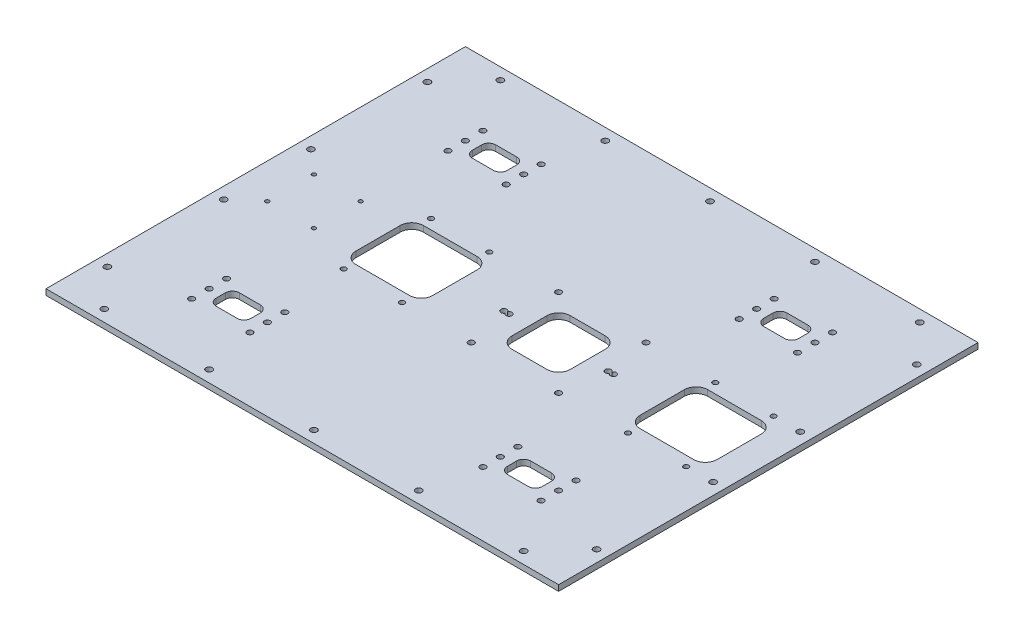
from build123d import *

# Parameters (mm, degrees)
ESQUISSE1_W             = 440
ESQUISSE1_H             = 360
ESQUISSE1_R             = 2.7
BOSS_EXTRU_1_DEPTH      = 5
ESQUISSE2_R             = 1.7
ESQUISSE2_R_2           = 2.5
ESQUISSE2_R_3           = 2.2
ESQUISSE2_W             = 66
ESQUISSE2_H             = 58
ESQUISSE2_W_2           = 50
ESQUISSE2_H_2           = 50
ENL_V_MAT_EXTRU_1_DEPTH = 6
CONG_1_R                = 10
ESQUISSE4_R             = 2.5
ESQUISSE4_W             = 30
ESQUISSE4_H             = 20
ENL_V_MAT_EXTRU_2_DEPTH = 10
CONG_2_R                = 6


with BuildPart() as part:
    # Esquisse1 → Boss.-Extru.1 (new body)
    with BuildSketch(Plane(origin=(0, 0, 0), x_dir=(1, 0, 0), z_dir=(0, 1, 0))):
        with Locations((220, 180)):
            Rectangle(ESQUISSE1_W, ESQUISSE1_H)
        with Locations((40, 350)):
            Circle(ESQUISSE1_R, mode=Mode.SUBTRACT)
        with Locations((130, 350)):
            Circle(ESQUISSE1_R, mode=Mode.SUBTRACT)
        with Locations((220, 350)):
            Circle(ESQUISSE1_R, mode=Mode.SUBTRACT)
        with Locations((310, 350)):
            Circle(ESQUISSE1_R, mode=Mode.SUBTRACT)
        with Locations((400, 350)):
            Circle(ESQUISSE1_R, mode=Mode.SUBTRACT)
        with Locations((400, 10)):
            Circle(ESQUISSE1_R, mode=Mode.SUBTRACT)
        with Locations((310, 10)):
            Circle(ESQUISSE1_R, mode=Mode.SUBTRACT)
        with Locations((220, 10)):
            Circle(ESQUISSE1_R, mode=Mode.SUBTRACT)
        with Locations((130, 10)):
            Circle(ESQUISSE1_R, mode=Mode.SUBTRACT)
        with Locations((40, 10)):
            Circle(ESQUISSE1_R, mode=Mode.SUBTRACT)
        with Locations((10, 217.36725867)):
            Circle(ESQUISSE1_R, mode=Mode.SUBTRACT)
        with Locations((10, 317.36725867)):
            Circle(ESQUISSE1_R, mode=Mode.SUBTRACT)
        with Locations((10, 42.63274133)):
            Circle(ESQUISSE1_R, mode=Mode.SUBTRACT)
        with Locations((10, 142.63274133)):
            Circle(ESQUISSE1_R, mode=Mode.SUBTRACT)
        with Locations((430, 142.63274133)):
            Circle(ESQUISSE1_R, mode=Mode.SUBTRACT)
        with Locations((430, 42.63274133)):
            Circle(ESQUISSE1_R, mode=Mode.SUBTRACT)
        with Locations((430, 317.36725867)):
            Circle(ESQUISSE1_R, mode=Mode.SUBTRACT)
        with Locations((430, 217.36725867)):
            Circle(ESQUISSE1_R, mode=Mode.SUBTRACT)
    extrude(amount=BOSS_EXTRU_1_DEPTH)

    # Esquisse2 → Enlèv. mat.-Extru.1 (cut, through all)
    with BuildSketch(Plane(origin=(0, 5, 0), x_dir=(1, 0, 0), z_dir=(0, 1, 0))):
        with Locations((30, 200)):
            Circle(ESQUISSE2_R)
        with Locations((70, 200)):
            Circle(ESQUISSE2_R)
        with Locations((70, 160)):
            Circle(ESQUISSE2_R)
        with Locations((30, 160)):
            Circle(ESQUISSE2_R)
        with Locations((222.5, 217.5)):
            Circle(ESQUISSE2_R_2)
        with Locations((297.5, 217.5)):
            Circle(ESQUISSE2_R_2)
        with Locations((222.5, 142.5)):
            Circle(ESQUISSE2_R_2)
        with Locations((297.5, 142.5)):
            Circle(ESQUISSE2_R_2)
        with Locations((407, 142.5)):
            Circle(ESQUISSE2_R_3)
        with Locations((357, 142.5)):
            Circle(ESQUISSE2_R_3)
        with Locations((357, 217.5)):
            Circle(ESQUISSE2_R_3)
        with Locations((407, 217.5)):
            Circle(ESQUISSE2_R_3)
        with Locations((163, 142.5)):
            Circle(ESQUISSE2_R_3)
        with Locations((113, 142.5)):
            Circle(ESQUISSE2_R_3)
        with Locations((113, 217.5)):
            Circle(ESQUISSE2_R_3)
        with Locations((163, 217.5)):
            Circle(ESQUISSE2_R_3)
        with Locations((138, 180)):
            Rectangle(ESQUISSE2_W, ESQUISSE2_H)
        with Locations((382, 180)):
            Rectangle(ESQUISSE2_W, ESQUISSE2_H)
        with Locations((260, 180)):
            Rectangle(ESQUISSE2_W_2, ESQUISSE2_H_2)
        with BuildLine():
            ThreePointArc((215.25, 181.089724736), (210.5, 180), (215.25, 178.910275264))
            ThreePointArc((215.25, 178.910275264), (220, 180), (215.25, 181.089724736))
        make_face()
        with BuildLine():
            ThreePointArc((304.75, 178.910275264), (309.5, 180), (304.75, 181.089724736))
            ThreePointArc((304.75, 181.089724736), (300, 180), (304.75, 178.910275264))
        make_face()
    extrude(amount=-ENL_V_MAT_EXTRU_1_DEPTH, mode=Mode.SUBTRACT)

    # Congé1
    cong_1_edges = [part.edges().sort_by_distance(p)[0] for p in [
        (415, 2.5, -209),
        (415, 2.5, -151),
        (349, 2.5, -151),
        (349, 2.5, -209),
        (105, 2.5, -151),
        (105, 2.5, -209),
        (171, 2.5, -209),
        (171, 2.5, -151),
        (285, 2.5, -205),
        (285, 2.5, -155),
        (235, 2.5, -155),
        (235, 2.5, -205),
    ]]
    fillet(cong_1_edges, radius=CONG_1_R)

    # Esquisse4 → Enlèv. mat.-Extru.2 (cut)
    with BuildSketch(Plane(origin=(0, 5, 0), x_dir=(1, 0, 0), z_dir=(0, 1, 0))):
        with Locations((70, 290)):
            Circle(ESQUISSE4_R)
        with Locations((120, 290)):
            Circle(ESQUISSE4_R)
        with Locations((70, 305)):
            Circle(ESQUISSE4_R)
        with Locations((70, 275)):
            Circle(ESQUISSE4_R)
        with Locations((120, 275)):
            Circle(ESQUISSE4_R)
        with Locations((120, 305)):
            Circle(ESQUISSE4_R)
        with Locations((320, 305)):
            Circle(ESQUISSE4_R)
        with Locations((320, 275)):
            Circle(ESQUISSE4_R)
        with Locations((370, 275)):
            Circle(ESQUISSE4_R)
        with Locations((370, 305)):
            Circle(ESQUISSE4_R)
        with Locations((320, 290)):
            Circle(ESQUISSE4_R)
        with Locations((370, 290)):
            Circle(ESQUISSE4_R)
        with Locations((370, 70)):
            Circle(ESQUISSE4_R)
        with Locations((320, 70)):
            Circle(ESQUISSE4_R)
        with Locations((370, 55)):
            Circle(ESQUISSE4_R)
        with Locations((370, 85)):
            Circle(ESQUISSE4_R)
        with Locations((320, 85)):
            Circle(ESQUISSE4_R)
        with Locations((320, 55)):
            Circle(ESQUISSE4_R)
        with Locations((120, 55)):
            Circle(ESQUISSE4_R)
        with Locations((120, 85)):
            Circle(ESQUISSE4_R)
        with Locations((70, 85)):
            Circle(ESQUISSE4_R)
        with Locations((70, 55)):
            Circle(ESQUISSE4_R)
        with Locations((120, 70)):
            Circle(ESQUISSE4_R)
        with Locations((70, 70)):
            Circle(ESQUISSE4_R)
        with Locations((95, 290)):
            Rectangle(ESQUISSE4_W, ESQUISSE4_H)
        with Locations((345, 290)):
            Rectangle(ESQUISSE4_W, ESQUISSE4_H)
        with Locations((345, 70)):
            Rectangle(ESQUISSE4_W, ESQUISSE4_H)
        with Locations((95, 70)):
            Rectangle(ESQUISSE4_W, ESQUISSE4_H)
    extrude(amount=-ENL_V_MAT_EXTRU_2_DEPTH, mode=Mode.SUBTRACT)

    # Congé2
    cong_2_edges = [part.edges().sort_by_distance(p)[0] for p in [
        (80, 2.5, -60),
        (80, 2.5, -80),
        (110, 2.5, -80),
        (110, 2.5, -60),
        (360, 2.5, -80),
        (360, 2.5, -60),
        (330, 2.5, -60),
        (330, 2.5, -80),
        (110, 2.5, -300),
        (110, 2.5, -280),
        (80, 2.5, -280),
        (80, 2.5, -300),
        (360, 2.5, -300),
        (360, 2.5, -280),
        (330, 2.5, -280),
        (330, 2.5, -300),
    ]]
    fillet(cong_2_edges, radius=CONG_2_R)


solid = part.part
